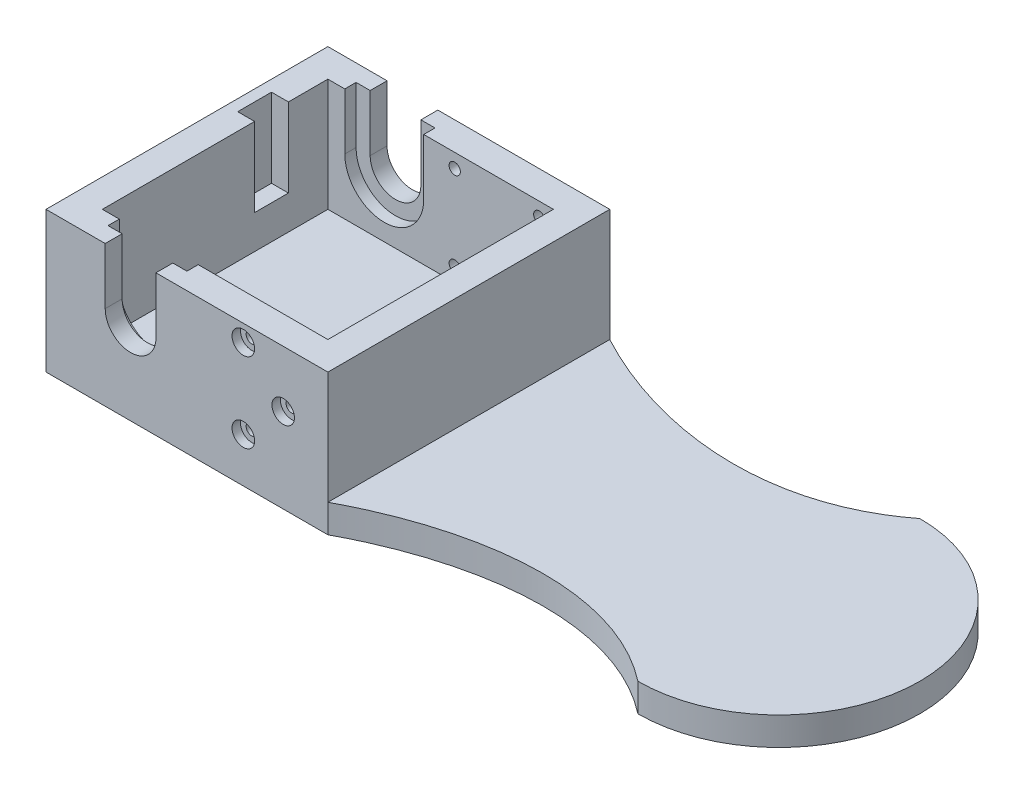
from build123d import *

# Parameters (mm, degrees)
SALIENTE_EXTRUIR1_DEPTH    = 25
CROQUIS2_W                 = 40
CROQUIS2_H                 = 40
CORTAR_EXTRUIR1_DEPTH      = 20
CORTAR_EXTRUIR2_DEPTH      = 70
CORTAR_EXTRUIR2_DEPTH_BACK = 20
CORTAR_EXTRUIR3_DEPTH      = 42
CORTAR_EXTRUIR3_DEPTH_BACK = 2
CROQUIS8_R                 = 1
CORTAR_EXTRUIR7_DEPTH      = 10
CROQUIS9_R                 = 1
CORTAR_EXTRUIR8_DEPTH      = 10
CROQUIS10_R                = 2
CORTAR_EXTRUIR9_DEPTH      = 1.5
CROQUIS11_R                = 2
CORTAR_EXTRUIR10_DEPTH     = 1.5
CORTAR_EXTRUIR11_DEPTH     = 70
CORTAR_EXTRUIR12_DEPTH     = 10
CORTAR_EXTRUIR13_DEPTH     = 10
CROQUIS14_W                = 3
CROQUIS14_H                = 6
CORTAR_EXTRUIR14_DEPTH     = 14


with BuildPart() as part:
    # Croquis1 → Saliente-Extruir1 (new body)
    with BuildSketch(Plane(origin=(0, 0, 0), x_dir=(1, 0, 0), z_dir=(0, 1, 0))):
        Polygon((-5, 45), (-5, 0), (-5, -5), (125, -5), (125, 45), align=None)
    extrude(amount=SALIENTE_EXTRUIR1_DEPTH)

    # Croquis2 → Cortar-Extruir1 (cut)
    with BuildSketch(Plane(origin=(0, 25, 0), x_dir=(1, 0, 0), z_dir=(0, 1, 0))):
        with Locations((20, 20)):
            Rectangle(CROQUIS2_W, CROQUIS2_H)
    extrude(amount=-CORTAR_EXTRUIR1_DEPTH, mode=Mode.SUBTRACT)

    # Croquis3 → Cortar-Extruir2 (cut, two sides)
    with BuildSketch(Plane.XY.offset(-40)) as cortar_extruir2_sk:
        with BuildLine():
            ThreePointArc((5.5, 15), (10, 19.5), (14.5, 15))
            Line((14.5, 15), (14.5, 25))
            Line((14.5, 25), (5.5, 25))
            Line((5.5, 25), (5.5, 15))
        make_face()
        with BuildLine():
            ThreePointArc((5.5, 15), (10, 10.5), (14.5, 15))
            Line((14.5, 15), (5.5, 15))
        make_face()
        with BuildLine():
            Line((5.5, 15), (14.5, 15))
            ThreePointArc((14.5, 15), (10, 19.5), (5.5, 15))
        make_face()
    extrude(amount=CORTAR_EXTRUIR2_DEPTH, mode=Mode.SUBTRACT)
    extrude(cortar_extruir2_sk.sketch, amount=-CORTAR_EXTRUIR2_DEPTH_BACK, mode=Mode.SUBTRACT)

    # Croquis4 → Cortar-Extruir3 (cut, two sides)
    with BuildSketch(Plane.XY.offset(-40)) as cortar_extruir3_sk:
        with BuildLine():
            Line((14.5, 15), (17, 15))
            ThreePointArc((17, 15), (16.34428877, 17.958039892), (14.5, 20.361902647))
            Line((14.5, 20.361902647), (14.5, 15))
        make_face()
        with BuildLine():
            ThreePointArc((3, 15), (10, 8), (17, 15))
            Line((17, 15), (14.5, 15))
            ThreePointArc((14.5, 15), (10, 10.5), (5.5, 15))
            Line((5.5, 15), (3, 15))
        make_face()
        with BuildLine():
            ThreePointArc((5.5, 20.361902647), (3.65571123, 17.958039892), (3, 15))
            Line((3, 15), (5.5, 15))
            Line((5.5, 15), (5.5, 20.361902647))
        make_face()
        with BuildLine():
            Line((3, 25), (3, 15))
            ThreePointArc((3, 15), (3.65571123, 17.958039892), (5.5, 20.361902647))
            Line((5.5, 20.361902647), (5.5, 25))
            Line((5.5, 25), (3, 25))
        make_face()
        with BuildLine():
            ThreePointArc((14.5, 20.361902647), (16.34428877, 17.958039892), (17, 15))
            Line((17, 15), (17, 25))
            Line((17, 25), (14.5, 25))
            Line((14.5, 25), (14.5, 20.361902647))
        make_face()
    extrude(amount=CORTAR_EXTRUIR3_DEPTH, mode=Mode.SUBTRACT)
    extrude(cortar_extruir3_sk.sketch, amount=-CORTAR_EXTRUIR3_DEPTH_BACK, mode=Mode.SUBTRACT)

    # Croquis8 → Cortar-Extruir7 (cut)
    with BuildSketch(Plane.XY.offset(-40)):
        with Locations((37.5, 22.5)):
            Circle(CROQUIS8_R)
        with Locations((37.5, 7.5)):
            Circle(CROQUIS8_R)
        with Locations((22.5, 7.5)):
            Circle(CROQUIS8_R)
        with Locations((22.5, 22.5)):
            Circle(CROQUIS8_R)
    extrude(amount=-CORTAR_EXTRUIR7_DEPTH, mode=Mode.SUBTRACT)

    # Croquis9 → Cortar-Extruir8 (cut)
    with BuildSketch(Plane(origin=(0, 0, 0), x_dir=(-1, 0, 0), z_dir=(0, 0, -1))):
        with Locations((-30, 22.071067812)):
            Circle(CROQUIS9_R)
        with Locations((-37.071067812, 15)):
            Circle(CROQUIS9_R)
        with Locations((-30, 7.928932188)):
            Circle(CROQUIS9_R)
    extrude(amount=-CORTAR_EXTRUIR8_DEPTH, mode=Mode.SUBTRACT)

    # Croquis10 → Cortar-Extruir9 (cut)
    with BuildSketch(Plane(origin=(0, 0, -45), x_dir=(-1, 0, 0), z_dir=(0, 0, -1))):
        with Locations((-22.5, 22.5)):
            Circle(CROQUIS10_R)
        with Locations((-22.5, 7.5)):
            Circle(CROQUIS10_R)
        with Locations((-37.5, 7.5)):
            Circle(CROQUIS10_R)
        with Locations((-37.5, 22.5)):
            Circle(CROQUIS10_R)
    extrude(amount=-CORTAR_EXTRUIR9_DEPTH, mode=Mode.SUBTRACT)

    # Croquis11 → Cortar-Extruir10 (cut)
    with BuildSketch(Plane.XY.offset(5)):
        with Locations((30, 22.071067812)):
            Circle(CROQUIS11_R)
        with Locations((37.071067812, 15)):
            Circle(CROQUIS11_R)
        with Locations((30, 7.928932188)):
            Circle(CROQUIS11_R)
    extrude(amount=-CORTAR_EXTRUIR10_DEPTH, mode=Mode.SUBTRACT)

    # Croquis6 → Cortar-Extruir11 (cut)
    with BuildSketch(Plane.XY.offset(5)):
        with BuildLine():
            ThreePointArc((45, 14.616328231), (64.430156973, 7.437849736), (85, 5))
            ThreePointArc((85, 5), (105.569843027, 7.437849736), (125, 14.616328231))
            Line((125, 14.616328231), (125, 25))
            Line((125, 25), (45, 25))
            Line((45, 25), (45, 14.616328231))
        make_face()
        with BuildLine():
            ThreePointArc((125, 14.616328231), (105.569843027, 7.437849736), (85, 5))
            Line((85, 5), (115.083217913, 5))
            ThreePointArc((115.083217913, 5), (120.099831147, 6.87798276), (125, 9.041677006))
            Line((125, 9.041677006), (125, 14.616328231))
        make_face()
        with BuildLine():
            ThreePointArc((125, 9.041677006), (120.099831147, 6.87798276), (115.083217913, 5))
            Line((115.083217913, 5), (125, 5))
            Line((125, 5), (125, 9.041677006))
        make_face()
        with BuildLine():
            Line((54.916782087, 5), (85, 5))
            ThreePointArc((85, 5), (64.430156973, 7.437849736), (45, 14.616328231))
            Line((45, 14.616328231), (45, 9.041677006))
            ThreePointArc((45, 9.041677006), (49.900168853, 6.87798276), (54.916782087, 5))
        make_face()
        with BuildLine():
            Line((45, 5), (54.916782087, 5))
            ThreePointArc((54.916782087, 5), (49.900168853, 6.87798276), (45, 9.041677006))
            Line((45, 9.041677006), (45, 5))
        make_face()
    extrude(amount=-CORTAR_EXTRUIR11_DEPTH, mode=Mode.SUBTRACT)

    # Croquis12 → Cortar-Extruir12 (cut)
    with BuildSketch(Plane(origin=(0, 5, 0), x_dir=(1, 0, 0), z_dir=(0, 1, 0))):
        Polygon((108.263538332, 57.3224396), (100, 45), (125, 45), (125, 20), (125, -5), (100, -5), (92.796515759, -13.049468459), (132.437262959, -23.501277263), (155.434902904, 7.824857744), (139.962048677, 54.254841825), align=None)
        with BuildLine():
            Line((125, -5), (125, 20))
            ThreePointArc((125, 20), (117.67766953, 2.32233047), (100, -5))
            Line((100, -5), (125, -5))
        make_face()
        with BuildLine():
            Line((125, 45), (100, 45))
            ThreePointArc((100, 45), (117.67766953, 37.67766953), (125, 20))
            Line((125, 20), (125, 45))
        make_face()
    extrude(amount=-CORTAR_EXTRUIR12_DEPTH, mode=Mode.SUBTRACT)

    # Croquis13 → Cortar-Extruir13 (cut)
    with BuildSketch(Plane(origin=(0, 5, 0), x_dir=(1, 0, 0), z_dir=(0, 1, 0))):
        with BuildLine():
            Line((100, 45), (136.076424828, 53.027802714))
            Line((136.076424828, 53.027802714), (154.686517999, 18.057188076))
            Line((154.686517999, 18.057188076), (135.411120125, -29.058819331))
            Line((135.411120125, -29.058819331), (100, -5))
            add(Edge.make_bspline(
                [(45, -5), (61.631849348, 3.922329445), (83.736441822, 7.63137214), (100, -5)],
                knots=[0, 0, 0, 0, 1, 1, 1, 1], degree=3))
            Line((45, -5), (-2.569566086, -27.480051403))
            Line((-2.569566086, -27.480051403), (140.150106541, -43.115071719))
            Line((140.150106541, -43.115071719), (174.827779806, 24.436234005))
            Line((174.827779806, 24.436234005), (136.076424828, 62.541584801))
            Line((136.076424828, 62.541584801), (45, 45))
            add(Edge.make_bspline(
                [(45, 45), (61.631849348, 36.077670555), (83.736441822, 32.36862786), (100, 45)],
                knots=[0, 0, 0, 0, 1, 1, 1, 1], degree=3))
        make_face()
    extrude(amount=-CORTAR_EXTRUIR13_DEPTH, mode=Mode.SUBTRACT)

    # Croquis14 → Cortar-Extruir14 (cut)
    with BuildSketch(Plane(origin=(0, 25, 0), x_dir=(1, 0, 0), z_dir=(0, 1, 0))):
        with Locations((-1.5, 30)):
            Rectangle(CROQUIS14_W, CROQUIS14_H)
    extrude(amount=-CORTAR_EXTRUIR14_DEPTH, mode=Mode.SUBTRACT)


solid = part.part
